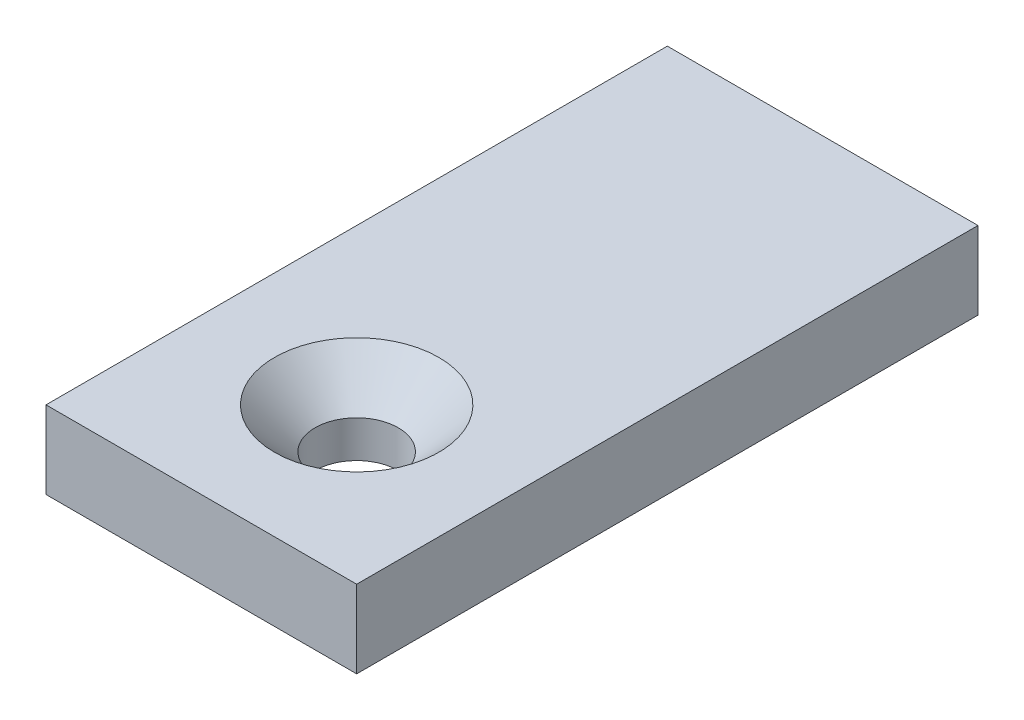
from build123d import *

# Parameters (mm, degrees)
SKETCH9_W           = 12.7
SKETCH9_H           = 25.4
BOSS_EXTRUDE1_DEPTH = 3.175


with BuildPart() as part:
    # Sketch9 → Boss-Extrude1 (new body)
    with BuildSketch(Plane(origin=(0, 0, 0), x_dir=(1, 0, 0), z_dir=(0, 1, 0))):
        with Locations((6.35, 12.7)):
            Rectangle(SKETCH9_W, SKETCH9_H)
    extrude(amount=BOSS_EXTRUDE1_DEPTH)

    # Sketch10 → CSK for M3 SFHCS2 (revolve, cut)
    with BuildSketch(Plane(origin=(6.35, 3.175, -6.35), x_dir=(0, 0, 1), z_dir=(1, 0, 0))):
        Polygon((0, 0), (0, 3.175), (1.7, 3.175), (1.7, 1.66), (3.36, 0), align=None)
    revolve(axis=Axis((6.35, 9.525, -6.35), (0, -1, 0)), mode=Mode.SUBTRACT)


solid = part.part
